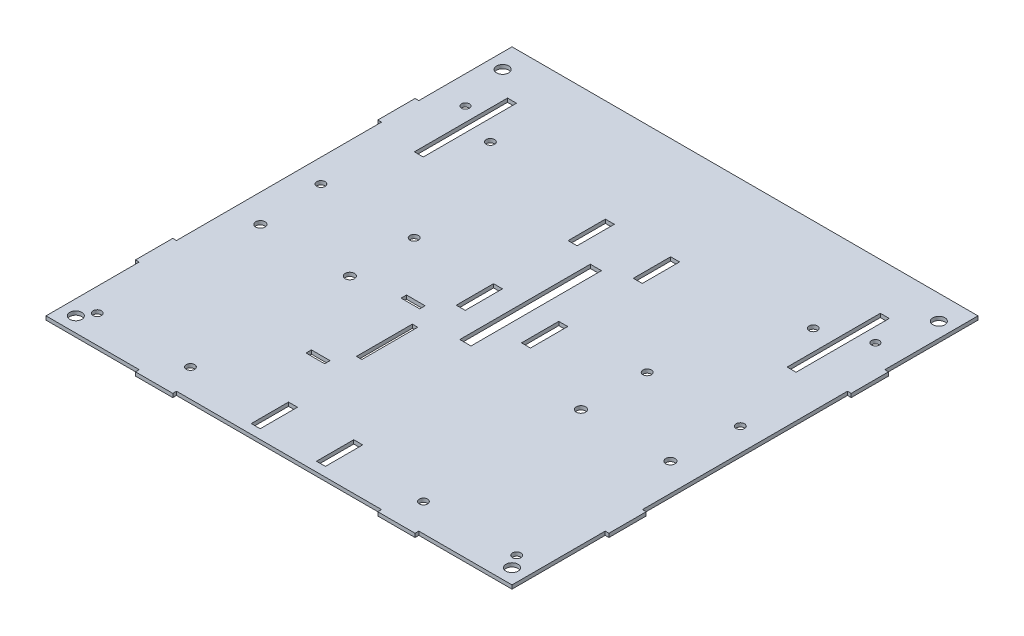
from build123d import *

# Parameters (mm, degrees)
SKETCH1_W                           = 250
SKETCH1_H                           = 250
SKETCH1_W_2                         = 4.8
SKETCH1_H_2                         = 20
SKETCH1_W_3                         = 10
SKETCH1_H_3                         = 2.9
SKETCH1_W_4                         = 2.9
SKETCH1_H_4                         = 30
SKETCH1_H_5                         = 50
SKETCH1_W_5                         = 6
SKETCH1_H_6                         = 70
BOSS_EXTRUDE1_DEPTH                 = 2
SKETCH2_R                           = 2.5
CUT_EXTRUDE1_DEPTH                  = 3
SKETCH3_R                           = 3.25
CUT_EXTRUDE2_DEPTH                  = 3
SKETCH4_W                           = 2
SKETCH4_H                           = 20
SKETCH4_W_2                         = 20
SKETCH4_H_2                         = 2
BOSS_EXTRUDE2_DEPTH                 = 2
F_4_5_4_5_DIAMETER_HOLE1_AT_2_COUNT = 2
F_4_5_4_5_DIAMETER_HOLE1_AT_2_PITCH = 50
F_4_5_4_5_DIAMETER_HOLE1_AT_3_COUNT = 2
F_4_5_4_5_DIAMETER_HOLE1_AT_3_PITCH = 130
F_4_5_4_5_DIAMETER_HOLE1_AT_4_COUNT = 2
F_4_5_4_5_DIAMETER_HOLE1_AT_4_PITCH = 120
SKETCH9_W                           = 4.8
SKETCH9_H                           = 20
CUT_EXTRUDE3_DEPTH                  = 3
SKETCH10_R                          = 2.1
CUT_EXTRUDE4_DEPTH                  = 5
SKETCH_1_R                          = 2.25
CUT_EXTRUDE_1_DEPTH                 = 2
CUT_EXTRUDE_1_DEPTH_BACK            = 10


with BuildPart() as part:
    # Sketch1 → Boss-Extrude1 (new body)
    with BuildSketch(Plane(origin=(0, 0, 0), x_dir=(1, 0, 0), z_dir=(0, 1, 0))):
        with Locations((125, 125)):
            Rectangle(SKETCH1_W, SKETCH1_H)
        with Locations((142.5, 15)):
            Rectangle(SKETCH1_W_2, SKETCH1_H_2, mode=Mode.SUBTRACT)
        with Locations((107.5, 15)):
            Rectangle(SKETCH1_W_2, SKETCH1_H_2, mode=Mode.SUBTRACT)
        with Locations((92, 53.93422616)):
            Rectangle(SKETCH1_W_3, SKETCH1_H_3, mode=Mode.SUBTRACT)
        with Locations((103.55, 79.434226159)):
            Rectangle(SKETCH1_W_4, SKETCH1_H_4, mode=Mode.SUBTRACT)
        with Locations((92, 104.93422616)):
            Rectangle(SKETCH1_W_3, SKETCH1_H_3, mode=Mode.SUBTRACT)
        with Locations((107.5, 125)):
            Rectangle(SKETCH1_W_2, SKETCH1_H_2, mode=Mode.SUBTRACT)
        with Locations((142.5, 125)):
            Rectangle(SKETCH1_W_2, SKETCH1_H_2, mode=Mode.SUBTRACT)
        with Locations((225, 200)):
            Rectangle(SKETCH1_W_2, SKETCH1_H_5, mode=Mode.SUBTRACT)
        with Locations((125, 135)):
            Rectangle(SKETCH1_W_5, SKETCH1_H_6, mode=Mode.SUBTRACT)
        with Locations((25, 200)):
            Rectangle(SKETCH1_W_2, SKETCH1_H_5, mode=Mode.SUBTRACT)
    extrude(amount=BOSS_EXTRUDE1_DEPTH)

    # Sketch2 → Cut-Extrude1 (cut, through all)
    with BuildSketch(Plane(origin=(0, 2, 0), x_dir=(1, 0, 0), z_dir=(0, 1, 0))):
        with Locations((15, 100)):
            Circle(SKETCH2_R)
        with Locations((63, 100)):
            Circle(SKETCH2_R)
    cut_extrude1 = extrude(amount=-CUT_EXTRUDE1_DEPTH, mode=Mode.SUBTRACT)

    # Sketch3 → Cut-Extrude2 (cut, through all)
    with BuildSketch(Plane(origin=(0, 2, 0), x_dir=(1, 0, 0), z_dir=(0, 1, 0))):
        with Locations((8, 8)):
            Circle(SKETCH3_R)
        with Locations((8, 237)):
            Circle(SKETCH3_R)
    cut_extrude2 = extrude(amount=-CUT_EXTRUDE2_DEPTH, mode=Mode.SUBTRACT)

    # Mirror1: Cut-Extrude2 across plane
    add(cut_extrude2.mirror(Plane.ZY.offset(-125)), mode=Mode.SUBTRACT)

    # Sketch4 → Boss-Extrude2 (add)
    with BuildSketch(Plane(origin=(0, 2, 0), x_dir=(1, 0, 0), z_dir=(0, 1, 0))):
        with Locations((-1, 190)):
            Rectangle(SKETCH4_W, SKETCH4_H)
        with Locations((-1, 60)):
            Rectangle(SKETCH4_W, SKETCH4_H)
        with Locations((60, -1)):
            Rectangle(SKETCH4_W_2, SKETCH4_H_2)
    boss_extrude2 = extrude(amount=-BOSS_EXTRUDE2_DEPTH)

    # Mirror2: Boss-Extrude2 across plane
    add(boss_extrude2.mirror(Plane.ZY.offset(-125)))

    # Mirror3: Cut-Extrude1 across plane
    add(cut_extrude1.mirror(Plane.ZY.offset(-125)), mode=Mode.SUBTRACT)

    # Sketch6 → Ø4.5 (4.5) Diameter Hole1 (revolve, cut)
    with BuildSketch(Plane(origin=(12.5, 2, -135), x_dir=(0, 0, 1), z_dir=(1, 0, 0))):
        Polygon((0, 0), (0, 11.351936393), (2.25, 10), (2.25, 0), align=None)
    f_4_5_4_5_diameter_hole1 = revolve(axis=Axis((12.5, 8.35, -135), (0, -1, 0)), mode=Mode.SUBTRACT)

    # Ø4.5 (4.5) Diameter Hole1 at 2: Ø4.5 (4.5) Diameter Hole1 ×2
    with Locations(*[(i * F_4_5_4_5_DIAMETER_HOLE1_AT_2_PITCH, 0, 0) for i in range(1, F_4_5_4_5_DIAMETER_HOLE1_AT_2_COUNT)]):
        add(f_4_5_4_5_diameter_hole1, mode=Mode.SUBTRACT)

    # Ø4.5 (4.5) Diameter Hole1 at 3: Ø4.5 (4.5) Diameter Hole1 ×2
    with Locations(*[Vector(0.384615385, 0, 0.923076923) * (i * F_4_5_4_5_DIAMETER_HOLE1_AT_3_PITCH) for i in range(1, F_4_5_4_5_DIAMETER_HOLE1_AT_3_COUNT)]):
        add(f_4_5_4_5_diameter_hole1, mode=Mode.SUBTRACT)

    # Ø4.5 (4.5) Diameter Hole1 at 4: Ø4.5 (4.5) Diameter Hole1 ×2
    with Locations(*[(0, 0, i * F_4_5_4_5_DIAMETER_HOLE1_AT_4_PITCH) for i in range(1, F_4_5_4_5_DIAMETER_HOLE1_AT_4_COUNT)]):
        add(f_4_5_4_5_diameter_hole1, mode=Mode.SUBTRACT)

    # Mirror4: Ø4.5 (4.5) Diameter Hole1 across plane
    add(f_4_5_4_5_diameter_hole1.mirror(Plane.ZY.offset(-125)), mode=Mode.SUBTRACT)

    # Mirror4 copy 1 sketch → Mirror4 copy 1 (revolve, cut)
    with BuildSketch(Plane(origin=(187.5, 2, -135), x_dir=(0, 0, 1), z_dir=(-1, 0, 0))):
        Polygon((0, 0), (0, -11.351936393), (2.25, -10), (2.25, 0), align=None)
    revolve(axis=Axis((187.5, 8.35, -135), (0, 1, 0)), mode=Mode.SUBTRACT)

    # Mirror4 copy 2 sketch → Mirror4 copy 2 (revolve, cut)
    with BuildSketch(Plane(origin=(187.5, 2, -15), x_dir=(0, 0, 1), z_dir=(-1, 0, 0))):
        Polygon((0, 0), (0, -11.351936393), (2.25, -10), (2.25, 0), align=None)
    revolve(axis=Axis((187.5, 8.35, -15), (0, 1, 0)), mode=Mode.SUBTRACT)

    # Mirror4 copy 3 sketch → Mirror4 copy 3 (revolve, cut)
    with BuildSketch(Plane(origin=(237.5, 2, -15), x_dir=(0, 0, 1), z_dir=(-1, 0, 0))):
        Polygon((0, 0), (0, -11.351936393), (2.25, -10), (2.25, 0), align=None)
    revolve(axis=Axis((237.5, 8.35, -15), (0, 1, 0)), mode=Mode.SUBTRACT)

    # Sketch9 → Cut-Extrude3 (cut, through all)
    with BuildSketch(Plane.XZ):
        with Locations((107.5, -185)):
            Rectangle(SKETCH9_W, SKETCH9_H)
    cut_extrude3 = extrude(amount=-CUT_EXTRUDE3_DEPTH, mode=Mode.SUBTRACT)

    # Mirror5: Cut-Extrude3 across plane
    add(cut_extrude3.mirror(Plane.ZY.offset(-125)), mode=Mode.SUBTRACT)

    # Sketch10 → Cut-Extrude4 (cut)
    with BuildSketch(Plane.XZ):
        with Locations((15, -210)):
            Circle(SKETCH10_R)
        with Locations((235, -210)):
            Circle(SKETCH10_R)
    extrude(amount=-CUT_EXTRUDE4_DEPTH, mode=Mode.SUBTRACT)

    # 草图1 → 切除-拉伸1 (cut, two sides)
    with BuildSketch(Plane(origin=(0, 0, 0), x_dir=(1, 0, 0), z_dir=(0, 1, 0))) as cut_extrude_1_sk:
        with Locations((38.4, 200)):
            Circle(SKETCH_1_R)
        with Locations((211.6, 200)):
            Circle(SKETCH_1_R)
    extrude(amount=CUT_EXTRUDE_1_DEPTH, mode=Mode.SUBTRACT)
    extrude(cut_extrude_1_sk.sketch, amount=-CUT_EXTRUDE_1_DEPTH_BACK, mode=Mode.SUBTRACT)


solid = part.part
